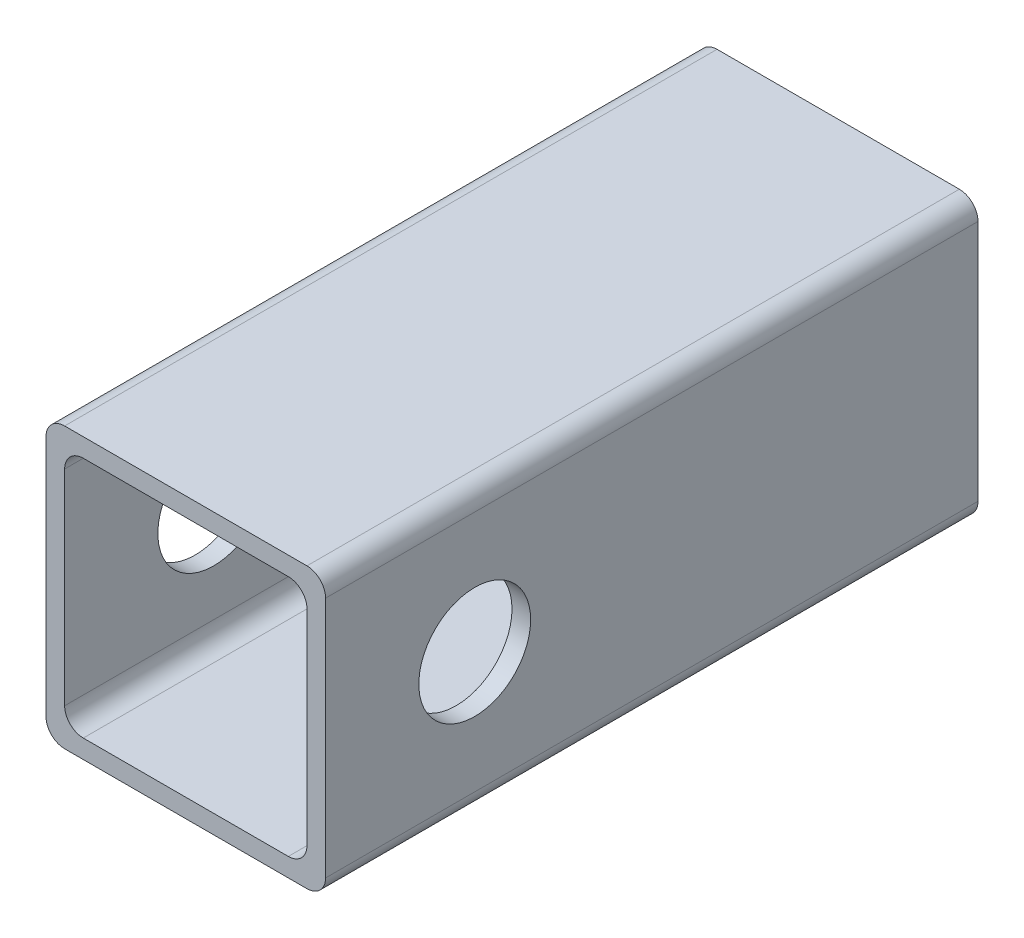
from build123d import *

# Parameters (mm, degrees)
DODANIE_WYCI_GNI_CIE2_DEPTH = 70
SZKIC2_R                    = 6
WYTNIJ_WYCI_GNI_CIE1_DEPTH  = 100


with BuildPart() as part:
    # Szkic1 → Dodanie-wyciągnięcie2 (new body)
    with BuildSketch(Plane.XY):
        with BuildLine():
            Line((2, 0), (28, 0))
            ThreePointArc((28, 0), (29.414213562, 0.585786438), (30, 2))
            Line((30, 2), (30, 28))
            ThreePointArc((30, 28), (29.414213562, 29.414213562), (28, 30))
            Line((28, 30), (2, 30))
            ThreePointArc((2, 30), (0.585786438, 29.414213562), (0, 28))
            Line((0, 28), (0, 2))
            ThreePointArc((0, 2), (0.585786438, 0.585786438), (2, 0))
        make_face()
        with BuildLine():
            Line((4, 28), (26, 28))
            ThreePointArc((26, 28), (27.414213562, 27.414213562), (28, 26))
            Line((28, 26), (28, 4))
            ThreePointArc((28, 4), (27.414213562, 2.585786438), (26, 2))
            Line((26, 2), (4, 2))
            ThreePointArc((4, 2), (2.585786438, 2.585786438), (2, 4))
            Line((2, 4), (2, 26))
            ThreePointArc((2, 26), (2.585786438, 27.414213562), (4, 28))
        make_face(mode=Mode.SUBTRACT)
    extrude(amount=DODANIE_WYCI_GNI_CIE2_DEPTH)

    # Szkic2 → Wytnij-wyciągnięcie1 (cut)
    with BuildSketch(Plane(origin=(30, 0, 0), x_dir=(0, 0, -1), z_dir=(1, 0, 0))):
        with Locations((-54, 15)):
            Circle(SZKIC2_R)
    extrude(amount=-WYTNIJ_WYCI_GNI_CIE1_DEPTH, mode=Mode.SUBTRACT)


solid = part.part
